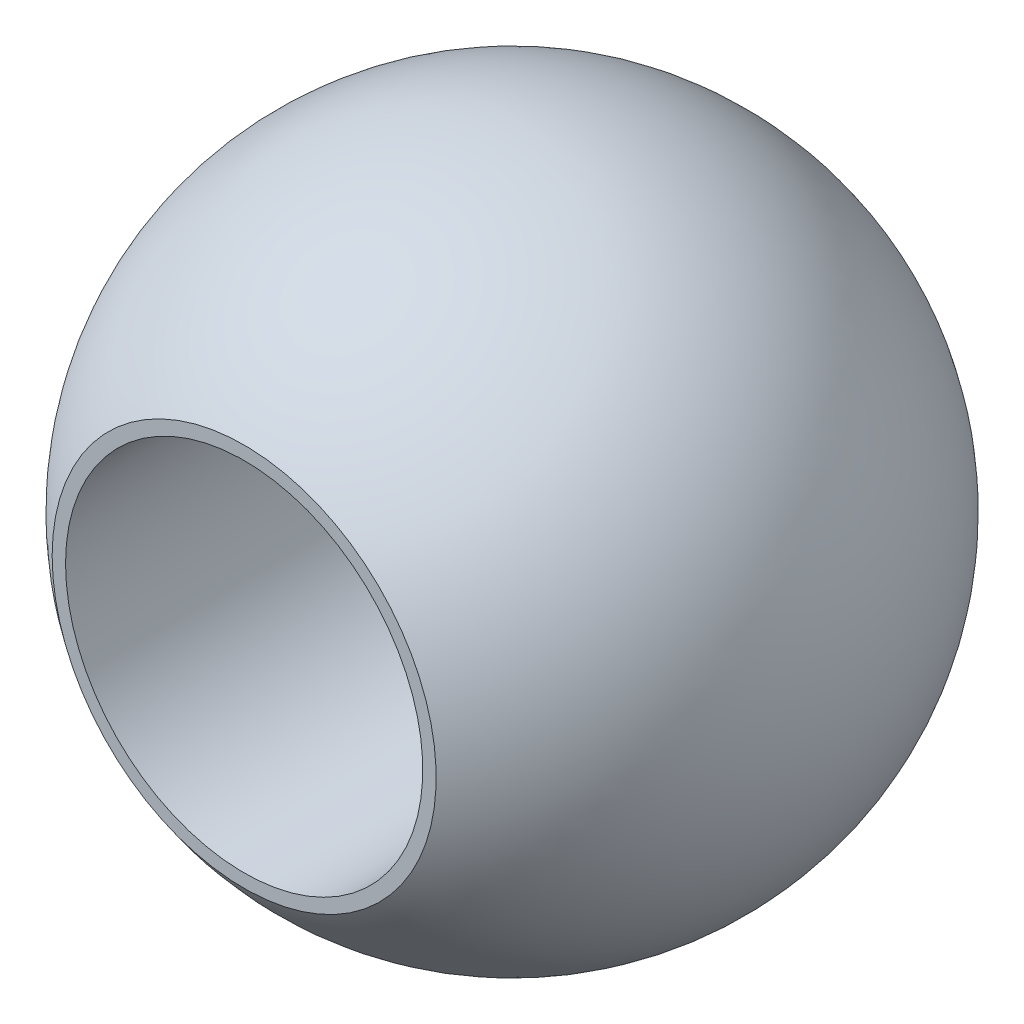
from build123d import *


with BuildPart() as part:
    # Sketch1 → Revolve1 (revolve)
    with BuildSketch(Plane(origin=(0, 0, 0), x_dir=(1, 0, 0), z_dir=(0, 1, 0))):
        with BuildLine():
            Line((4, 6), (4, -6))
            Line((4, -6), (4.3, -6))
            ThreePointArc((4.3, -6), (7.381734214, 0), (4.3, 6))
            Line((4.3, 6), (4, 6))
        make_face()
    revolve(axis=Axis((0, 0, 0), (0, 0, 1)))


solid = part.part
